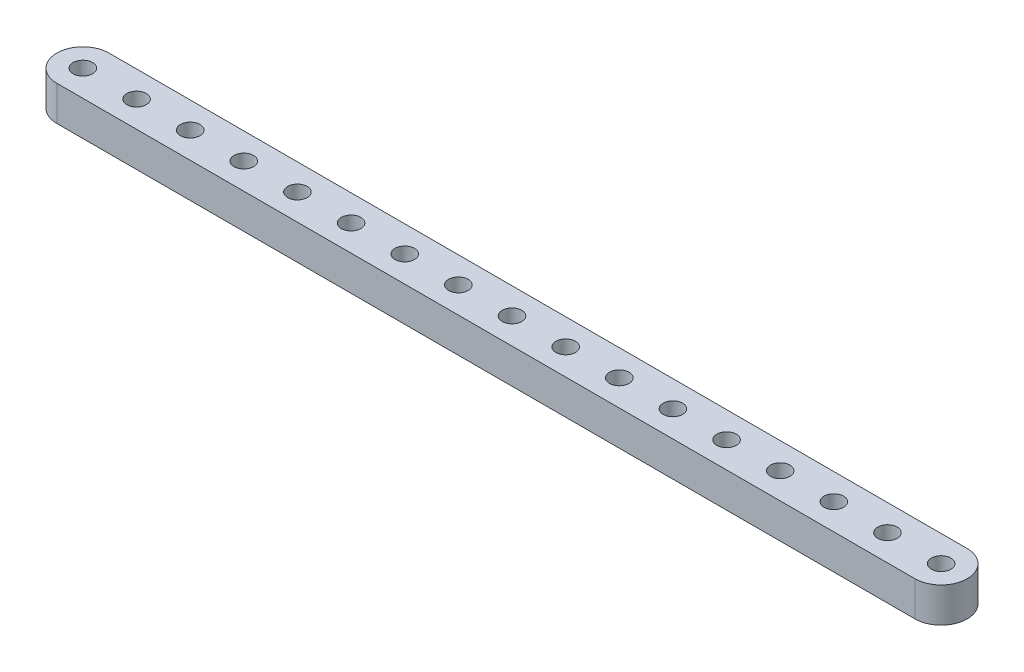
from build123d import *

# Parameters (mm, degrees)
SKETCH1_R           = 1.778
BOSS_EXTRUDE1_DEPTH = 6.35


with BuildPart() as part:
    # Sketch1 → Boss-Extrude1 (new body)
    with BuildSketch(Plane(origin=(0, 6.35, 0), x_dir=(1, 0, 0), z_dir=(0, 1, 0))):
        with BuildLine():
            Line((78.232, 4.7625), (-78.232, 4.7625))
            ThreePointArc((-78.232, 4.7625), (-82.9945, 0), (-78.232, -4.7625))
            Line((-78.232, -4.7625), (78.232, -4.7625))
            ThreePointArc((78.232, -4.7625), (82.9945, 0), (78.232, 4.7625))
        make_face()
        with Locations((78.232, 0)):
            Circle(SKETCH1_R, mode=Mode.SUBTRACT)
        with Locations((68.453, 0)):
            Circle(SKETCH1_R, mode=Mode.SUBTRACT)
        with Locations((58.674, 0)):
            Circle(SKETCH1_R, mode=Mode.SUBTRACT)
        with Locations((48.895, 0)):
            Circle(SKETCH1_R, mode=Mode.SUBTRACT)
        with Locations((39.116, 0)):
            Circle(SKETCH1_R, mode=Mode.SUBTRACT)
        with Locations((29.337, 0)):
            Circle(SKETCH1_R, mode=Mode.SUBTRACT)
        with Locations((19.558, 0)):
            Circle(SKETCH1_R, mode=Mode.SUBTRACT)
        with Locations((9.779, 0)):
            Circle(SKETCH1_R, mode=Mode.SUBTRACT)
        Circle(SKETCH1_R, mode=Mode.SUBTRACT)
        with Locations((-9.779, 0)):
            Circle(SKETCH1_R, mode=Mode.SUBTRACT)
        with Locations((-19.558, 0)):
            Circle(SKETCH1_R, mode=Mode.SUBTRACT)
        with Locations((-29.337, 0)):
            Circle(SKETCH1_R, mode=Mode.SUBTRACT)
        with Locations((-39.116, 0)):
            Circle(SKETCH1_R, mode=Mode.SUBTRACT)
        with Locations((-48.895, 0)):
            Circle(SKETCH1_R, mode=Mode.SUBTRACT)
        with Locations((-58.674, 0)):
            Circle(SKETCH1_R, mode=Mode.SUBTRACT)
        with Locations((-68.453, 0)):
            Circle(SKETCH1_R, mode=Mode.SUBTRACT)
        with Locations((-78.232, 0)):
            Circle(SKETCH1_R, mode=Mode.SUBTRACT)
    extrude(amount=-BOSS_EXTRUDE1_DEPTH)


solid = part.part
